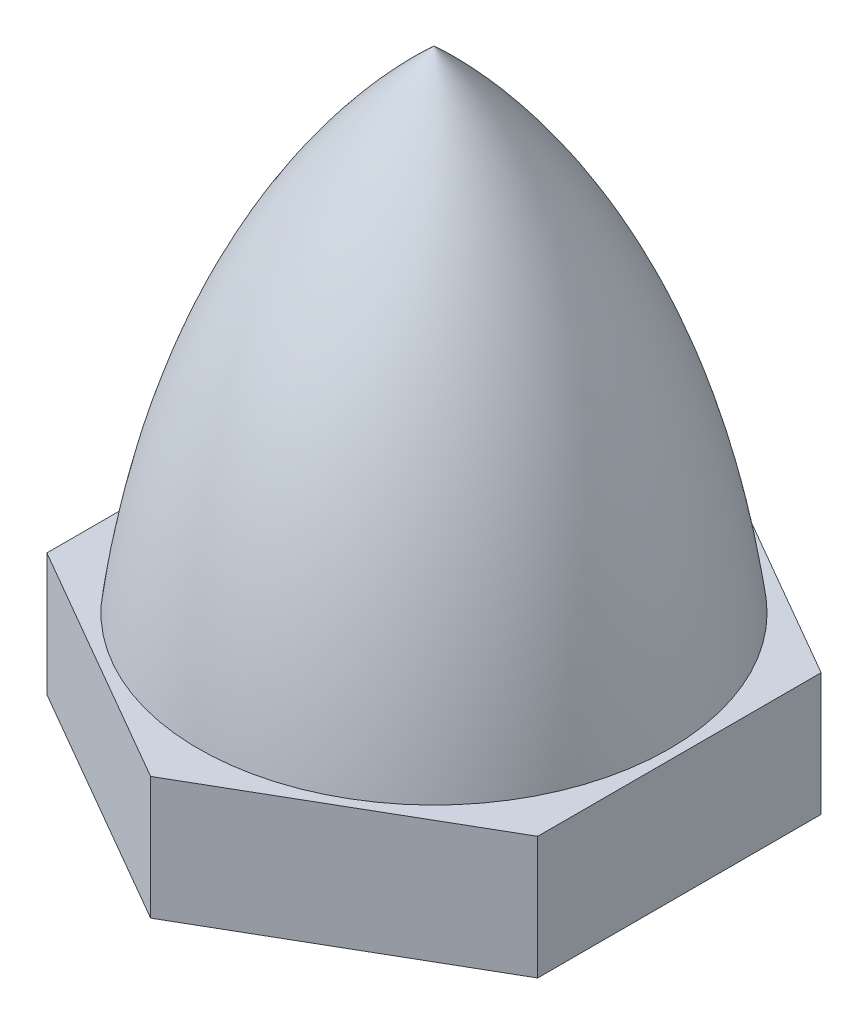
from build123d import *

# Parameters (mm, degrees)
EXTRUDE_1_DEPTH = 3
M6X1_01_D       = 5
M6X1_01_DEPTH   = 9


with BuildPart() as part:
    # Эскиз1 → Повернуть1 (revolve)
    with BuildSketch(Plane.XY):
        with BuildLine():
            Line((0, 0), (0, 15))
            add(Edge.make_bspline(
                [(0, 15), (5.663028189, 9.794830304), (6, 0)],
                knots=[0, 0, 0, 1, 1, 1], degree=2))
            Line((6, 0), (0, 0))
        make_face()
    revolve(axis=Axis((0, 0, 0), (0, 1, 0)))

    # Эскиз2 → Бобышка-Вытянуть1 (add)
    with BuildSketch(Plane.XZ):
        Polygon((0, 6.92820323), (-6, 3.464101615), (-6, -3.464101615), (0, -6.92820323), (6, -3.464101615), (6, 3.464101615), align=None)
    extrude(amount=-EXTRUDE_1_DEPTH)

    # Отверстие обработанное метчиком M6x1.01
    with Locations(Plane(origin=(0, 0, 0), x_dir=(-1, 0, 0), z_dir=(0, -1, 0))):
        with Locations((0, 0)):
            Hole(M6X1_01_D / 2, depth=M6X1_01_DEPTH)


solid = part.part
